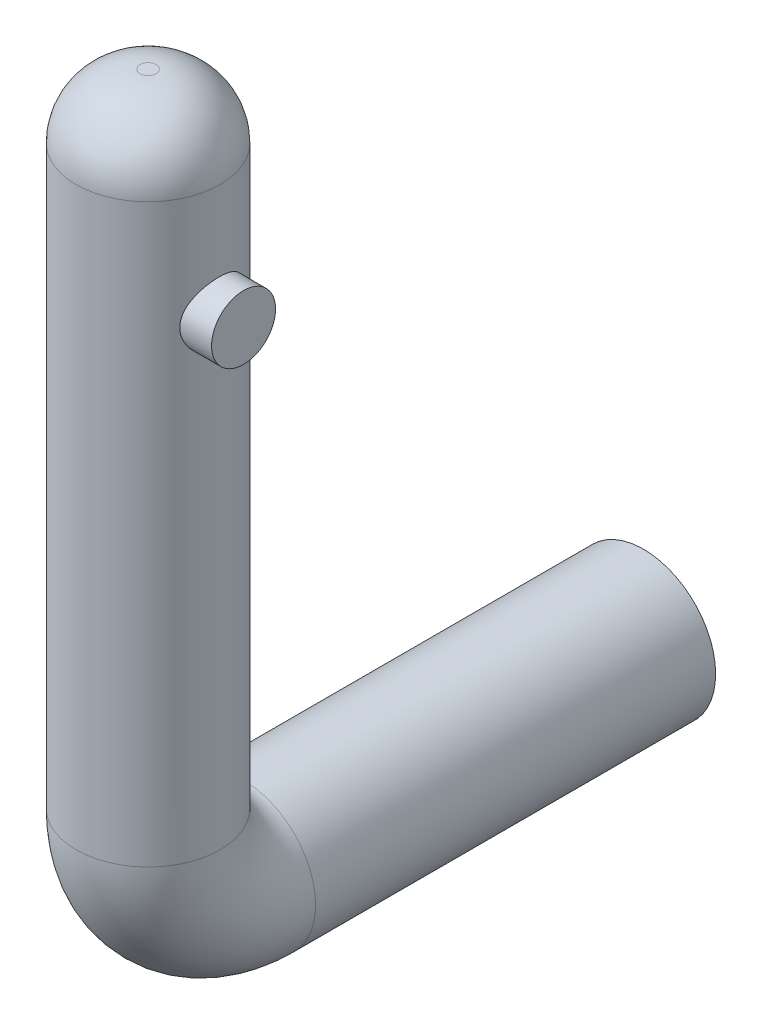
from build123d import *

# Parameters (mm, degrees)
SKETCH2_R           = 4.5
FILLET2_R           = 4
SKETCH4_R           = 2
BOSS_EXTRUDE1_DEPTH = 6


with BuildPart() as part:
    # Sweep3: sweep along a path in Sketch3
    with BuildLine(Plane(origin=(0, 0, 0), x_dir=(0, 0, -1), z_dir=(1, 0, 0))) as sweep3_path:
        Line((0, 0), (-25, 0))
        ThreePointArc((-25, 0), (-29.217732486, 1.747041998), (-30.964774484, 5.964774484))
        Line((-30.964774484, 5.964774484), (-30.964774484, 45.964774484))
    # Sketch2 → Sweep3 (sweep)
    with BuildSketch(Plane.XY):
        Circle(SKETCH2_R)
    sweep(path=sweep3_path.line)

    # Fillet2
    fillet2_edges = [part.edges().sort_by_distance(p)[0] for p in [
        (-4.5, 45.964774484, 30.964774484),
    ]]
    fillet(fillet2_edges, radius=FILLET2_R)

    # Sketch4 → Boss-Extrude1 (add)
    with BuildSketch(Plane(origin=(0, 0, 0), x_dir=(0, 0, -1), z_dir=(1, 0, 0))):
        with Locations((-31, 35)):
            Circle(SKETCH4_R)
    extrude(amount=BOSS_EXTRUDE1_DEPTH)


solid = part.part
